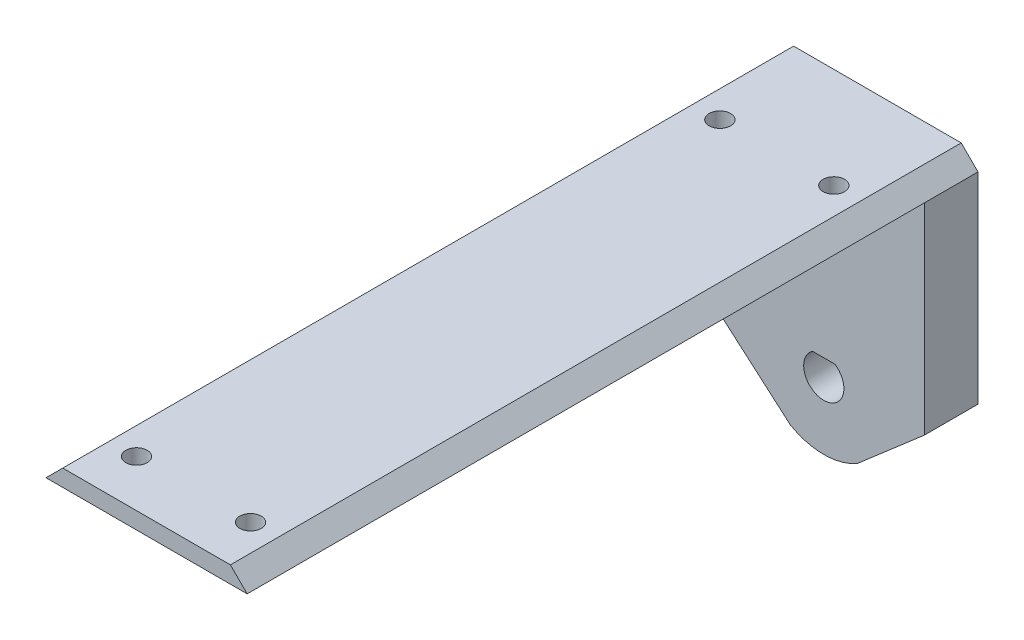
from build123d import *

# Parameters (mm, degrees)
BOSS_EXTRUDE1_DEPTH  = 8
BOSS_EXTRUDE3_DEPTH  = 109
M3_CLEARANCE_SLOT1_D = 3.2


with BuildPart() as part:
    # Sketch1 → Boss-Extrude1 (new body)
    with BuildSketch(Plane.XY):
        with BuildLine():
            Line((15, 23), (-15, 23))
            Line((-15, 23), (-15, -7))
            Line((-15, -7), (-5, -15.660254038))
            ThreePointArc((-5, -15.660254038), (0, -17), (5, -15.660254038))
            Line((5, -15.660254038), (15, -7))
            Line((15, -7), (15, 23))
        make_face()
        with BuildLine():
            Line((1.658312395, -4.5), (-1.658312395, -4.5))
            ThreePointArc((-1.658312395, -4.5), (0, -10), (1.658312395, -4.5))
        make_face(mode=Mode.SUBTRACT)
    extrude(amount=BOSS_EXTRUDE1_DEPTH)

    # Sketch1_5 → Boss-Extrude3 (add)
    with BuildSketch(Plane.XY):
        Polygon((-12.5, 25.5), (12.5, 25.5), (15, 23), (-15, 23), align=None)
    extrude(amount=BOSS_EXTRUDE3_DEPTH)

    # M3 Clearance Slot1 (through all)
    with Locations(Plane(origin=(0, 25.5, 0), x_dir=(1, 0, 0), z_dir=(0, 1, 0))):
        with Locations((-8.5, -15), (8.5, -15), (-8.5, -102), (8.5, -102)):
            Hole(M3_CLEARANCE_SLOT1_D / 2)


solid = part.part
